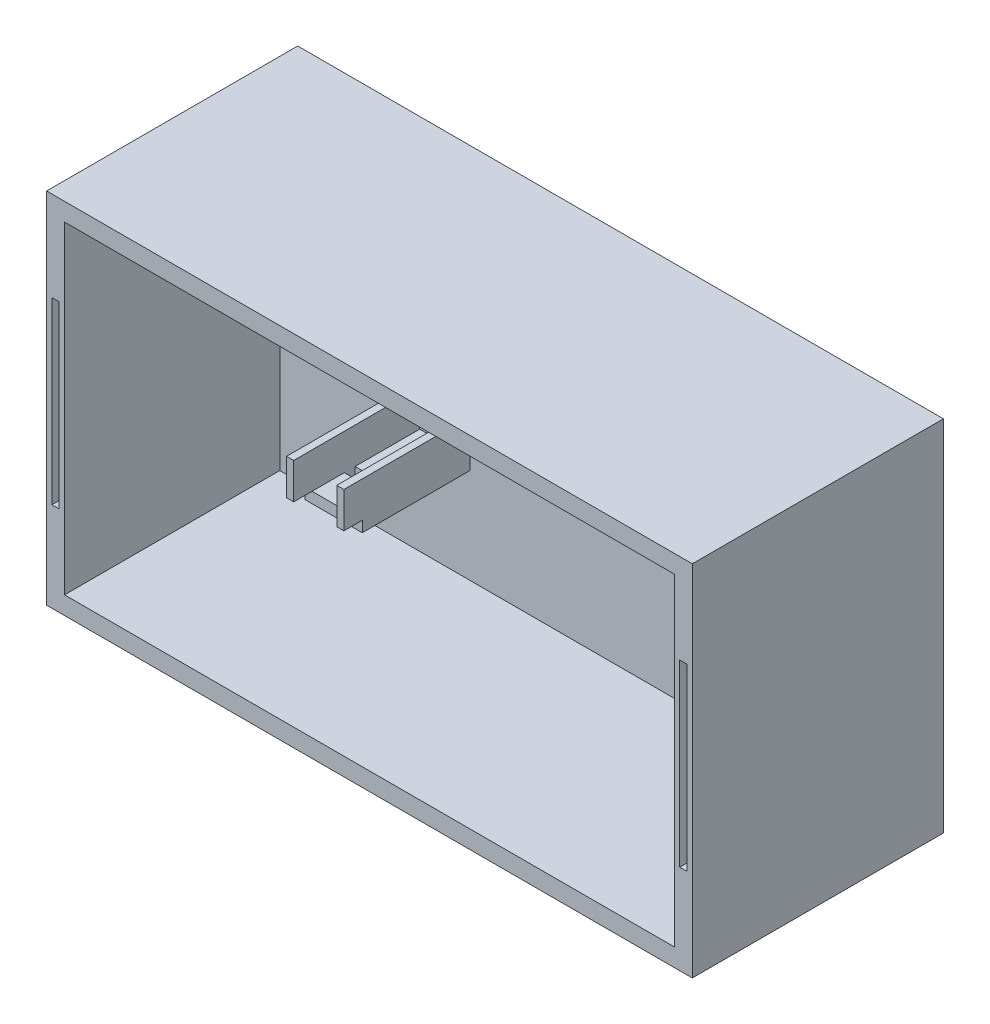
from build123d import *

# Parameters (mm, degrees)
SCHIZZO1_W                   = 180
SCHIZZO1_H                   = 60
ESTRUSIONE_ESTRUSIONE1_DEPTH = 5
SCHIZZO1_3_W                 = 180
SCHIZZO1_3_H                 = 10
ESTRUSIONE_ESTRUSIONE2_DEPTH = 100
SCHIZZO2_W                   = 180
SCHIZZO2_H                   = 5
ESTRUSIONE_ESTRUSIONE3_DEPTH = 60
SCHIZZO3_W                   = 5
SCHIZZO3_H                   = 90
ESTRUSIONE_ESTRUSIONE4_DEPTH = 60
SCHIZZO4_W                   = 12
SCHIZZO4_H                   = 3
TAGLIO_ESTRUSIONE1_DEPTH     = 90
SCHIZZO6_W                   = 2
SCHIZZO6_H                   = 15.540639337
ESTRUSIONE_ESTRUSIONE5_DEPTH = 10
SCHIZZO10_W                  = 16
SCHIZZO10_H                  = 3
ESTRUSIONE_ESTRUSIONE7_DEPTH = 30
SCHIZZO11_W                  = 12
SCHIZZO11_H                  = 3
TAGLIO_ESTRUSIONE6_DEPTH     = 5
SCHIZZO12_W                  = 9
SCHIZZO12_H                  = 3
TAGLIO_ESTRUSIONE7_DEPTH     = 20
SCHIZZO13_W                  = 2
SCHIZZO13_H                  = 35.114164676
ESTRUSIONE_ESTRUSIONE8_DEPTH = 10
TAGLIO_ESTRUSIONE8_START     = -15.540639
SCHIZZO15_W                  = 21.926890516
SCHIZZO15_H                  = 11.981890919
TAGLIO_ESTRUSIONE8_DEPTH     = 15.540639
SCHIZZO16_W                  = 12
SCHIZZO16_H                  = 3
ESTRUSIONE_ESTRUSIONE9_DEPTH = 5
SCHIZZO17_R                  = 9.5
TAGLIO_ESTRUSIONE9_DEPTH     = 6
SCHIZZO21_W                  = 2
SCHIZZO21_H                  = 50
TAGLIO_ESTRUSIONE10_DEPTH    = 2


with BuildPart() as part:
    # Schizzo1 → Estrusione-Estrusione1 (new body)
    with BuildSketch(Plane(origin=(0, 0, 0), x_dir=(1, 0, 0), z_dir=(0, 1, 0))):
        with Locations((90, 30)):
            Rectangle(SCHIZZO1_W, SCHIZZO1_H)
    extrude(amount=ESTRUSIONE_ESTRUSIONE1_DEPTH)

    # Schizzo1_3 → Estrusione-Estrusione2 (add)
    with BuildSketch(Plane(origin=(0, 0, 0), x_dir=(1, 0, 0), z_dir=(0, 1, 0))):
        with Locations((90, 65)):
            Rectangle(SCHIZZO1_3_W, SCHIZZO1_3_H)
    extrude(amount=ESTRUSIONE_ESTRUSIONE2_DEPTH)

    # Schizzo2 → Estrusione-Estrusione3 (add)
    with BuildSketch(Plane.XY.offset(-60)):
        with Locations((90, 97.5)):
            Rectangle(SCHIZZO2_W, SCHIZZO2_H)
    extrude(amount=ESTRUSIONE_ESTRUSIONE3_DEPTH)

    # Schizzo3 → Estrusione-Estrusione4 (add)
    with BuildSketch(Plane.XY.offset(-60)):
        with Locations((2.5, 50)):
            Rectangle(SCHIZZO3_W, SCHIZZO3_H)
        with Locations((177.5, 50)):
            Rectangle(SCHIZZO3_W, SCHIZZO3_H)
    extrude(amount=ESTRUSIONE_ESTRUSIONE4_DEPTH)

    # Schizzo4 → Taglio-Estrusione1 (cut)
    with BuildSketch(Plane(origin=(0, 5, 0), x_dir=(1, 0, 0), z_dir=(0, 1, 0))):
        with Locations((50, 40.5)):
            Rectangle(SCHIZZO4_W, SCHIZZO4_H)
    extrude(amount=-TAGLIO_ESTRUSIONE1_DEPTH, mode=Mode.SUBTRACT)

    # Schizzo6 → Estrusione-Estrusione5 (add)
    with BuildSketch(Plane(origin=(0, 5, 0), x_dir=(1, 0, 0), z_dir=(0, 1, 0))):
        with Locations((43, 41.770319669)):
            Rectangle(SCHIZZO6_W, SCHIZZO6_H)
        with Locations((57, 41.770319669)):
            Rectangle(SCHIZZO6_W, SCHIZZO6_H)
    extrude(amount=ESTRUSIONE_ESTRUSIONE5_DEPTH)

    # Schizzo10 → Estrusione-Estrusione7 (add)
    with BuildSketch(Plane.XY.offset(-60)):
        with Locations((50, 33)):
            Rectangle(SCHIZZO10_W, SCHIZZO10_H)
    extrude(amount=ESTRUSIONE_ESTRUSIONE7_DEPTH)

    # Schizzo11 → Taglio-Estrusione6 (cut)
    with BuildSketch(Plane.XZ.offset(-31.5)):
        with Locations((50, -40.5)):
            Rectangle(SCHIZZO11_W, SCHIZZO11_H)
    extrude(amount=-TAGLIO_ESTRUSIONE6_DEPTH, mode=Mode.SUBTRACT)

    # Schizzo12 → Taglio-Estrusione7 (cut)
    with BuildSketch(Plane.XY.offset(-60)):
        with Locations((50, 59)):
            Rectangle(SCHIZZO12_W, SCHIZZO12_H)
    extrude(amount=-TAGLIO_ESTRUSIONE7_DEPTH, mode=Mode.SUBTRACT)

    # Schizzo13 → Estrusione-Estrusione8 (add)
    with BuildSketch(Plane(origin=(0, 34.5, 0), x_dir=(1, 0, 0), z_dir=(0, 1, 0))):
        with Locations((43, 42.442917662)):
            Rectangle(SCHIZZO13_W, SCHIZZO13_H)
        with Locations((57, 42.442917662)):
            Rectangle(SCHIZZO13_W, SCHIZZO13_H)
    extrude(amount=ESTRUSIONE_ESTRUSIONE8_DEPTH)

    # Schizzo15 → Taglio-Estrusione8 (cut)
    with BuildSketch(Plane.XY.offset(-34).offset(TAGLIO_ESTRUSIONE8_START)):
        with Locations((49.332767586, 10.99094546)):
            Rectangle(SCHIZZO15_W, SCHIZZO15_H)
    extrude(amount=TAGLIO_ESTRUSIONE8_DEPTH, mode=Mode.SUBTRACT)

    # Schizzo16 → Estrusione-Estrusione9 (add)
    with BuildSketch(Plane.XZ):
        with Locations((50, -40.5)):
            Rectangle(SCHIZZO16_W, SCHIZZO16_H)
    extrude(amount=-ESTRUSIONE_ESTRUSIONE9_DEPTH)

    # Schizzo17 → Taglio-Estrusione9 (cut)
    with BuildSketch(Plane.XY.offset(-60)):
        with Locations((126, 50.9)):
            Circle(SCHIZZO17_R)
    extrude(amount=-TAGLIO_ESTRUSIONE9_DEPTH, mode=Mode.SUBTRACT)

    # Schizzo21 → Taglio-Estrusione10 (cut)
    with BuildSketch(Plane.XY):
        with Locations((2.5, 50)):
            Rectangle(SCHIZZO21_W, SCHIZZO21_H)
        with Locations((177.5, 50)):
            Rectangle(SCHIZZO21_W, SCHIZZO21_H)
    extrude(amount=-TAGLIO_ESTRUSIONE10_DEPTH, mode=Mode.SUBTRACT)


solid = part.part
